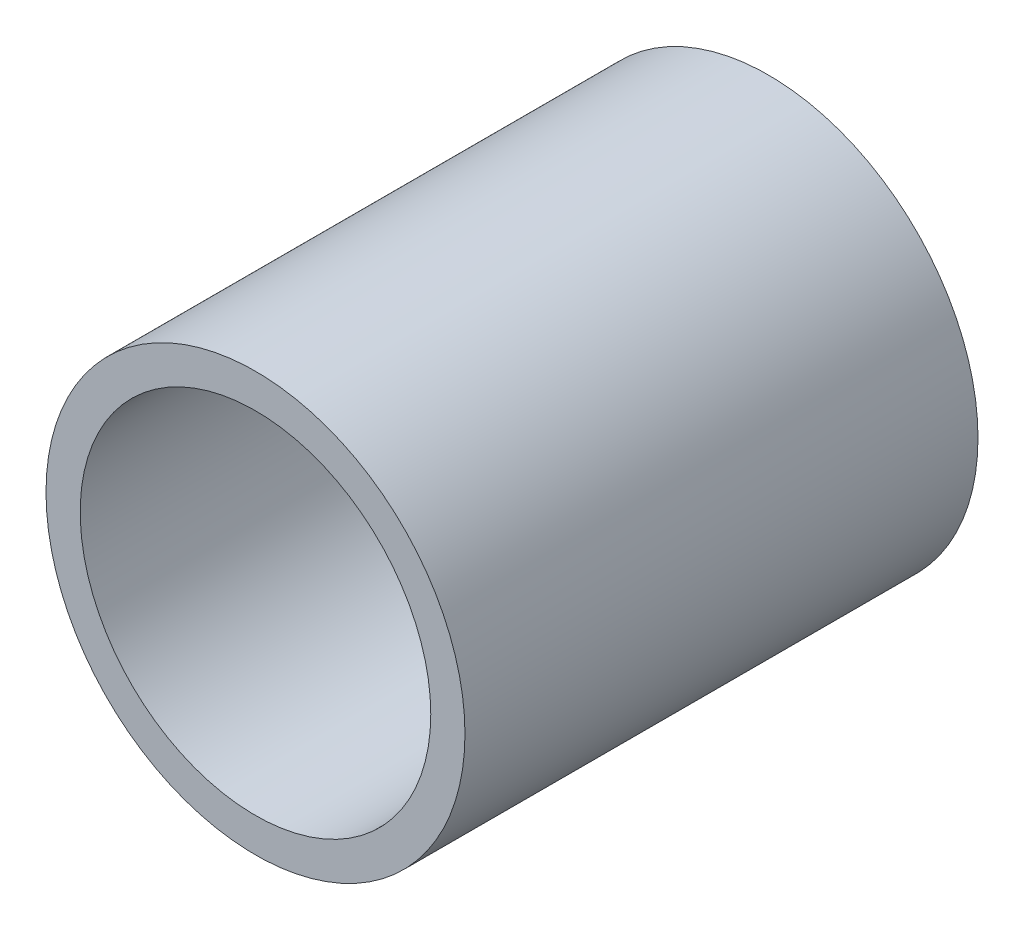
from build123d import *

# Parameters (mm, degrees)
SKETCH1_R           = 6.125
SKETCH1_R_2         = 5.125
BOSS_EXTRUDE1_DEPTH = 15


with BuildPart() as part:
    # Sketch1 → Boss-Extrude1 (new body)
    with BuildSketch(Plane.XY):
        Circle(SKETCH1_R)
        Circle(SKETCH1_R_2, mode=Mode.SUBTRACT)
    extrude(amount=BOSS_EXTRUDE1_DEPTH)


solid = part.part
